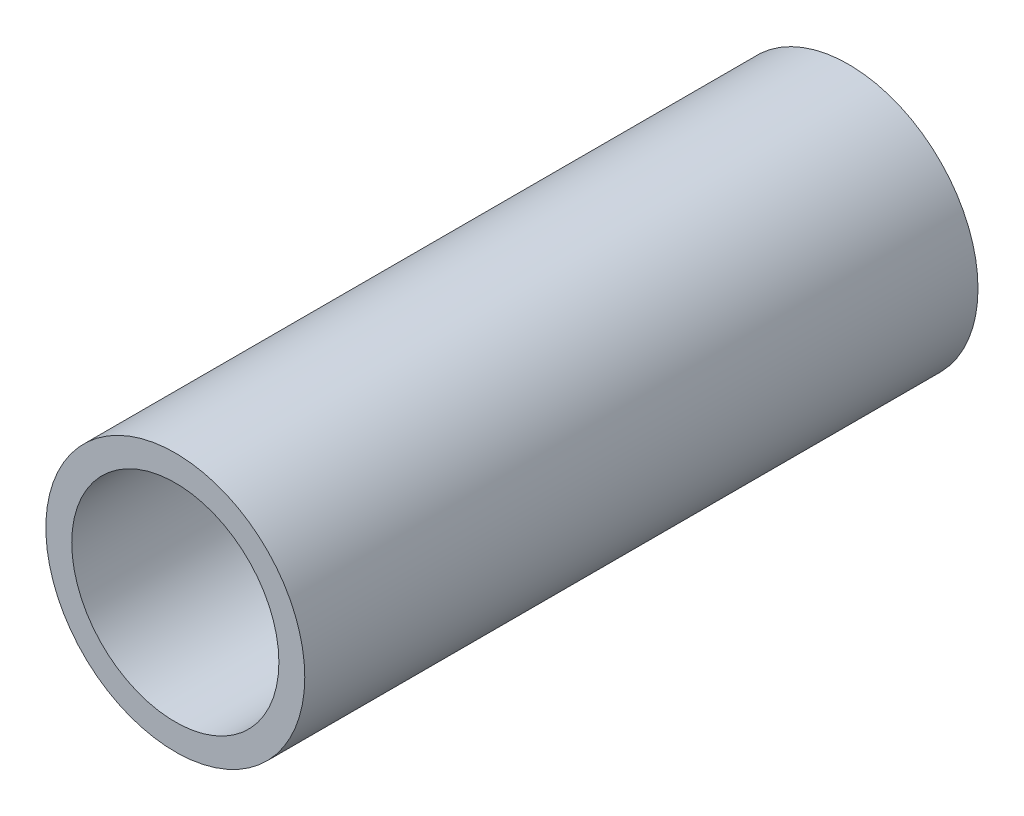
from build123d import *

# Parameters (mm, degrees)
SKETCH1_R           = 1.25
SKETCH1_R_2         = 1
BOSS_EXTRUDE1_DEPTH = 6.5


with BuildPart() as part:
    # Sketch1 → Boss-Extrude1 (new body)
    with BuildSketch(Plane.XY):
        Circle(SKETCH1_R)
        Circle(SKETCH1_R_2, mode=Mode.SUBTRACT)
    extrude(amount=BOSS_EXTRUDE1_DEPTH)


solid = part.part
